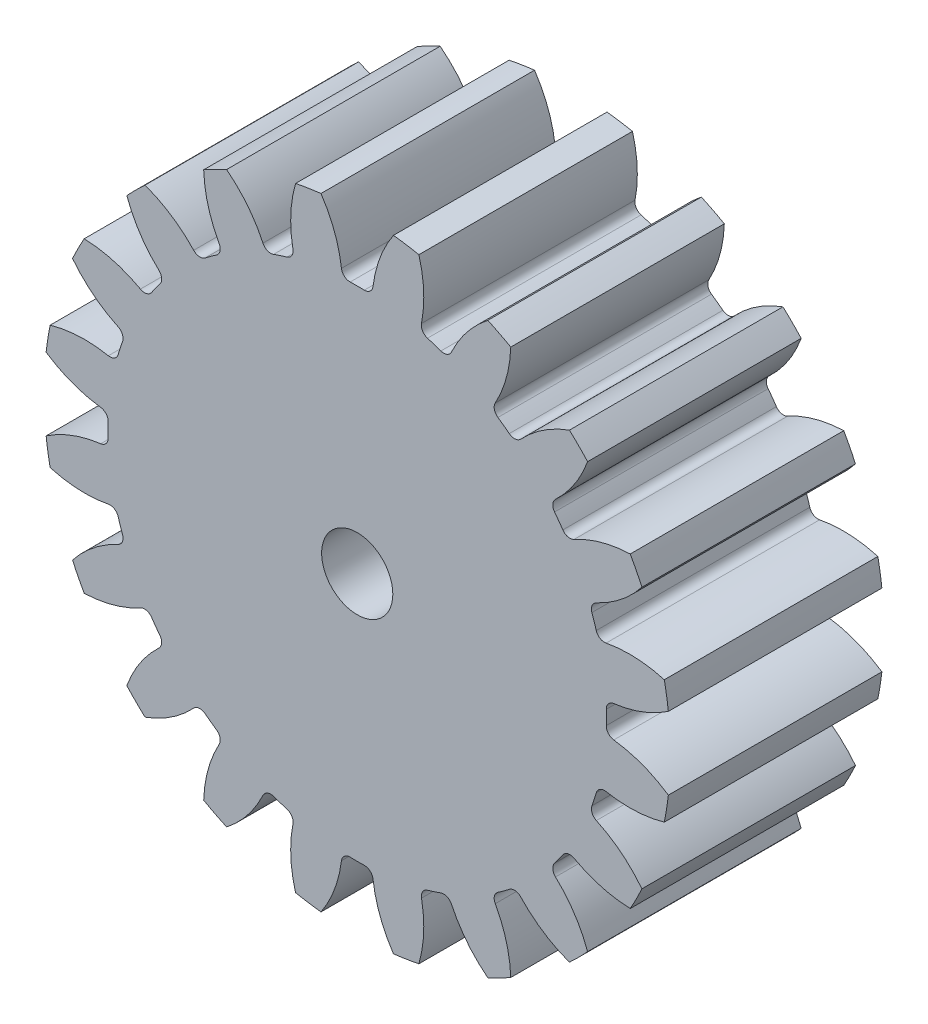
from build123d import *

# Parameters (mm, degrees)
SKBASE_R                                = 22
BASE_DEPTH                              = 7.5
TOOTHPROFILE_DEPTH                      = 8.5
FILLETTOOTHPROFILE_R                    = 0.6
CIRPATTERNTEETH_COUNT                   = 20
FILLETTOOTHPROFILE_OF_CIRPATTERNTEETH_R = 0.6
SKCHAVETA_R                             = 2.5
CHAVETA_DEPTH                           = 16.0000001


with BuildPart() as part:
    # skBase → Base (new body, symmetric)
    with BuildSketch(Plane.XY):
        Circle(SKBASE_R)
    extrude(amount=BASE_DEPTH, both=True)

    # skToothProfile → ToothProfile (cut, symmetric)
    with BuildSketch(Plane.XY):
        with BuildLine():
            ThreePointArc((-1.056260379, 17.468094172), (-1.711312383, 20.303280592), (-3.25795804, 22.768085326))
            ThreePointArc((-3.25795804, 22.768085326), (0, 23), (3.25795804, 22.768085326))
            ThreePointArc((3.25795804, 22.768085326), (1.711312383, 20.303280592), (1.056260379, 17.468094172))
            ThreePointArc((1.056260379, 17.468094172), (0, 17.5), (-1.056260379, 17.468094172))
        make_face()
    toothprofile = extrude(amount=TOOTHPROFILE_DEPTH, both=True, mode=Mode.SUBTRACT)

    # FilletToothProfile
    fillettoothprofile_edges = [part.edges().sort_by_distance(p)[0] for p in [
        (-1.056260379, 17.468094172, 0),
        (1.056260379, 17.468094172, 0),
    ]]
    fillet(fillettoothprofile_edges, radius=FILLETTOOTHPROFILE_R)

    # CirPatternTeeth: ToothProfile ×20 about axis
    cirpatternteeth_axis = Axis((0, 0, 0), (0, 0, 1))
    for i in range(1, CIRPATTERNTEETH_COUNT):
        add(toothprofile.rotate(cirpatternteeth_axis, i * 360 / CIRPATTERNTEETH_COUNT), mode=Mode.SUBTRACT)

    # FilletToothProfile of CirPatternTeeth
    fillettoothprofile_of_cirpatternteeth_edges = [part.edges().sort_by_distance(p)[0] for p in [
        (-6.402501275, 16.286742382, 0),
        (-4.393374642, 16.939547198, 0),
        (-11.122020738, 13.511130771, 0),
        (-9.412955543, 14.752839318, 0),
        (-14.752839318, 9.412955543, 0),
        (-13.511130771, 11.122020738, 0),
        (-16.939547198, 4.393374642, 0),
        (-16.286742382, 6.402501275, 0),
        (-17.468094172, -1.056260379, 0),
        (-17.468094172, 1.056260379, 0),
        (-16.286742382, -6.402501275, 0),
        (-16.939547198, -4.393374642, 0),
        (-13.511130771, -11.122020738, 0),
        (-14.752839318, -9.412955543, 0),
        (-9.412955543, -14.752839318, 0),
        (-11.122020738, -13.511130771, 0),
        (-4.393374642, -16.939547198, 0),
        (-6.402501275, -16.286742382, 0),
        (1.056260379, -17.468094172, 0),
        (-1.056260379, -17.468094172, 0),
        (6.402501275, -16.286742382, 0),
        (4.393374642, -16.939547198, 0),
        (11.122020738, -13.511130771, 0),
        (9.412955543, -14.752839318, 0),
        (14.752839318, -9.412955543, 0),
        (13.511130771, -11.122020738, 0),
        (16.939547198, -4.393374642, 0),
        (16.286742382, -6.402501275, 0),
        (17.468094172, 1.056260379, 0),
        (17.468094172, -1.056260379, 0),
        (16.286742382, 6.402501275, 0),
        (16.939547198, 4.393374642, 0),
        (13.511130771, 11.122020738, 0),
        (14.752839318, 9.412955543, 0),
        (9.412955543, 14.752839318, 0),
        (11.122020738, 13.511130771, 0),
        (4.393374642, 16.939547198, 0),
        (6.402501275, 16.286742382, 0),
    ]]
    fillet(fillettoothprofile_of_cirpatternteeth_edges, radius=FILLETTOOTHPROFILE_OF_CIRPATTERNTEETH_R)

    # skChaveta → Chaveta (cut, through all)
    with BuildSketch(Plane.XY.offset(7.5)):
        Circle(SKCHAVETA_R)
    extrude(amount=-CHAVETA_DEPTH, mode=Mode.SUBTRACT)


solid = part.part
